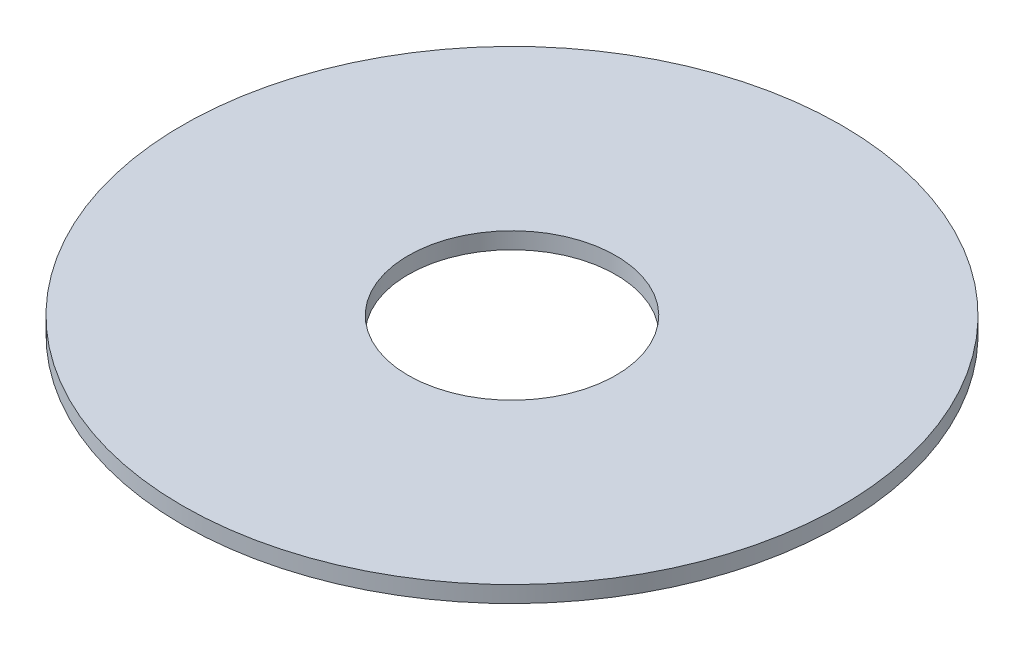
from build123d import *

# Parameters (mm, degrees)
SKETCH3_R           = 100
SKETCH3_R_2         = 31.5
BOSS_EXTRUDE2_DEPTH = 5


with BuildPart() as part:
    # Sketch3 → Boss-Extrude2 (new body)
    with BuildSketch(Plane(origin=(0, 0, 0), x_dir=(1, 0, 0), z_dir=(0, 1, 0))):
        Circle(SKETCH3_R)
        Circle(SKETCH3_R_2, mode=Mode.SUBTRACT)
    extrude(amount=BOSS_EXTRUDE2_DEPTH)


solid = part.part
